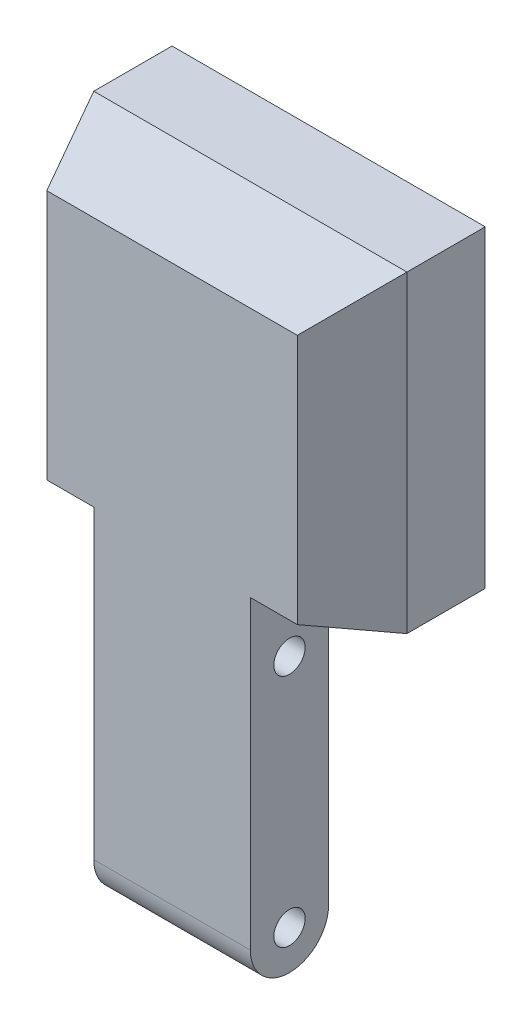
from build123d import *

# Parameters (mm, degrees)
CROQUIS1_W              = 20
CROQUIS1_H              = 40
SALIENTE_EXTRUIR1_DEPTH = 10
CROQUIS2_R              = 2
CORTAR_EXTRUIR1_DEPTH   = 31
CROQUIS3_W              = 40
CROQUIS3_H              = 10
SALIENTE_EXTRUIR2_DEPTH = 10
CROQUIS4_W              = 40
CROQUIS4_H              = 40
SALIENTE_EXTRUIR3_DEPTH = 20
CORTAR_EXTRUIR3_DEPTH   = 10
CORTAR_EXTRUIR4_DEPTH   = 10
CORTAR_EXTRUIR5_DEPTH   = 41
CORTAR_EXTRUIR6_DEPTH   = 40
CORTAR_EXTRUIR7_DEPTH   = 31


with BuildPart() as part:
    # Croquis1 → Saliente-Extruir1 (new body)
    with BuildSketch(Plane.XY):
        Rectangle(CROQUIS1_W, CROQUIS1_H)
        Polygon((0, 20), (10, 20), (20, 20), (20, 50), (0, 50), align=None)
        Polygon((-20, 20), (-10, 20), (0, 20), (0, 50), (-20, 50), align=None)
    extrude(amount=SALIENTE_EXTRUIR1_DEPTH)

    # Croquis2 → Cortar-Extruir1 (cut, through all)
    with BuildSketch(Plane(origin=(10, 0, 0), x_dir=(0, 0, -1), z_dir=(1, 0, 0))):
        with Locations((-5, -15)):
            Circle(CROQUIS2_R)
        with Locations((-5, 15)):
            Circle(CROQUIS2_R)
    extrude(amount=-CORTAR_EXTRUIR1_DEPTH, mode=Mode.SUBTRACT)

    # Croquis3 → Saliente-Extruir2 (add)
    with BuildSketch(Plane(origin=(0, 50, 0), x_dir=(1, 0, 0), z_dir=(0, 1, 0))):
        with Locations((0, -5)):
            Rectangle(CROQUIS3_W, CROQUIS3_H)
    extrude(amount=SALIENTE_EXTRUIR2_DEPTH)

    # Croquis4 → Saliente-Extruir3 (add)
    with BuildSketch(Plane.XY.offset(10)):
        with Locations((0, 40)):
            Rectangle(CROQUIS4_W, CROQUIS4_H)
    extrude(amount=-SALIENTE_EXTRUIR3_DEPTH)

    # Croquis6 → Cortar-Extruir3 (cut)
    with BuildSketch(Plane(origin=(20, 0, 0), x_dir=(0, 0, -1), z_dir=(1, 0, 0))):
        Polygon((-10, 20), (0, 20), (-10, 24), align=None)
    extrude(amount=-CORTAR_EXTRUIR3_DEPTH, mode=Mode.SUBTRACT)

    # Croquis7 → Cortar-Extruir4 (cut)
    with BuildSketch(Plane.ZY.offset(20)):
        Polygon((0, 20), (10, 24), (10, 20), align=None)
    extrude(amount=-CORTAR_EXTRUIR4_DEPTH, mode=Mode.SUBTRACT)

    # Croquis8 → Cortar-Extruir5 (cut, through all)
    with BuildSketch(Plane(origin=(20, 0, 0), x_dir=(0, 0, -1), z_dir=(1, 0, 0))):
        Polygon((-10, 56), (0, 60), (-10, 60), align=None)
    extrude(amount=-CORTAR_EXTRUIR5_DEPTH, mode=Mode.SUBTRACT)

    # Croquis9 → Cortar-Extruir6 (cut)
    with BuildSketch(Plane(origin=(0, 60, 0), x_dir=(1, 0, 0), z_dir=(0, 1, 0))):
        Polygon((-20, 0), (-20, -10), (-16, -10), align=None)
        Polygon((20, 0), (20, -10), (16, -10), align=None)
    extrude(amount=-CORTAR_EXTRUIR6_DEPTH, mode=Mode.SUBTRACT)

    # Croquis10 → Cortar-Extruir7 (cut, through all)
    with BuildSketch(Plane(origin=(10, 0, 0), x_dir=(0, 0, -1), z_dir=(1, 0, 0))):
        with BuildLine():
            ThreePointArc((0, -15), (-1.464466094, -18.535533906), (-5, -20))
            Line((-5, -20), (0, -20))
            Line((0, -20), (0, -15))
        make_face()
        with BuildLine():
            ThreePointArc((-5, -20), (-8.535533906, -18.535533906), (-10, -15))
            Line((-10, -15), (-10, -20))
            Line((-10, -20), (-5, -20))
        make_face()
    extrude(amount=-CORTAR_EXTRUIR7_DEPTH, mode=Mode.SUBTRACT)


solid = part.part
